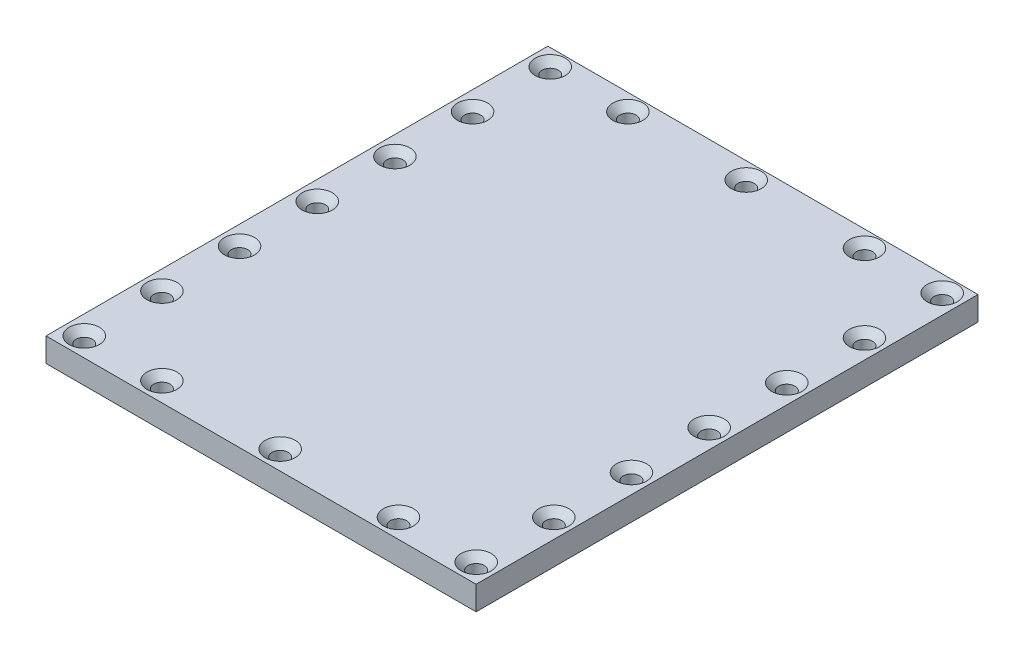
from build123d import *

# Parameters (mm, degrees)
SKETCH1_W                                           = 90
SKETCH1_H                                           = 105
EXTRUDE1_DEPTH                                      = 5
CSK_FOR_M3_COUNTERSUNK_FLAT_HEAD_SCREW1_D           = 3.4
CSK_FOR_M3_COUNTERSUNK_FLAT_HEAD_SCREW1_CSINK_D     = 6.3
CSK_FOR_M3_COUNTERSUNK_FLAT_HEAD_SCREW1_CSINK_ANGLE = 90
EXTRUDE2_START                                      = -5
EXTRUDE2_DEPTH                                      = 0.75


with BuildPart() as part:
    # Sketch1 → Extrude1 (new body)
    with BuildSketch(Plane(origin=(0, 0, 0), x_dir=(1, 0, 0), z_dir=(0, 1, 0))):
        with Locations((45, 52.5)):
            Rectangle(SKETCH1_W, SKETCH1_H)
    extrude(amount=EXTRUDE1_DEPTH)

    # CSK for M3 Countersunk Flat Head Screw1 (through all)
    with Locations(Plane(origin=(4, 5, -4), x_dir=(0, 0, 1), z_dir=(0, 1, 0))):
        with Locations((0, 0), (-16.25, 0), (-32.5, 0), (-48.75, 0), (-65, 0), (-81.25, 0), (-97.5, 0), (-97.5, 16.25), (-97.5, 41), (-97.5, 65.75), (-97.5, 82), (-81.25, 82), (-65, 82), (-48.75, 82), (-32.5, 82), (-16.25, 82), (0, 82), (0, 65.75), (0, 41), (0, 16.25)):
            CounterSinkHole(CSK_FOR_M3_COUNTERSUNK_FLAT_HEAD_SCREW1_D / 2, CSK_FOR_M3_COUNTERSUNK_FLAT_HEAD_SCREW1_CSINK_D / 2, counter_sink_angle=CSK_FOR_M3_COUNTERSUNK_FLAT_HEAD_SCREW1_CSINK_ANGLE)

    # Sketch2 → Extrude2 (cut)
    with BuildSketch(Plane(origin=(0, 5, 0), x_dir=(1, 0, 0), z_dir=(0, 1, 0)).offset(EXTRUDE2_START)):
        with BuildLine():
            Line((16, 7), (74, 7))
            ThreePointArc((74, 7), (80.363961031, 9.636038969), (83, 16))
            Line((83, 16), (83, 89.5))
            ThreePointArc((83, 89.5), (80.363961031, 95.863961031), (74, 98.5))
            Line((74, 98.5), (16, 98.5))
            ThreePointArc((16, 98.5), (9.636038969, 95.863961031), (7, 89.5))
            Line((7, 89.5), (7, 16))
            ThreePointArc((7, 16), (9.636038969, 9.636038969), (16, 7))
        make_face()
        with BuildLine():
            Line((9, 89.5), (9, 16))
            ThreePointArc((9, 16), (11.050252532, 11.050252532), (16, 9))
            Line((16, 9), (74, 9))
            ThreePointArc((74, 9), (78.949747468, 11.050252532), (81, 16))
            Line((81, 16), (81, 89.5))
            ThreePointArc((81, 89.5), (78.949747468, 94.449747468), (74, 96.5))
            Line((74, 96.5), (16, 96.5))
            ThreePointArc((16, 96.5), (11.050252532, 94.449747468), (9, 89.5))
        make_face(mode=Mode.SUBTRACT)
    extrude(amount=EXTRUDE2_DEPTH, mode=Mode.SUBTRACT)


solid = part.part
